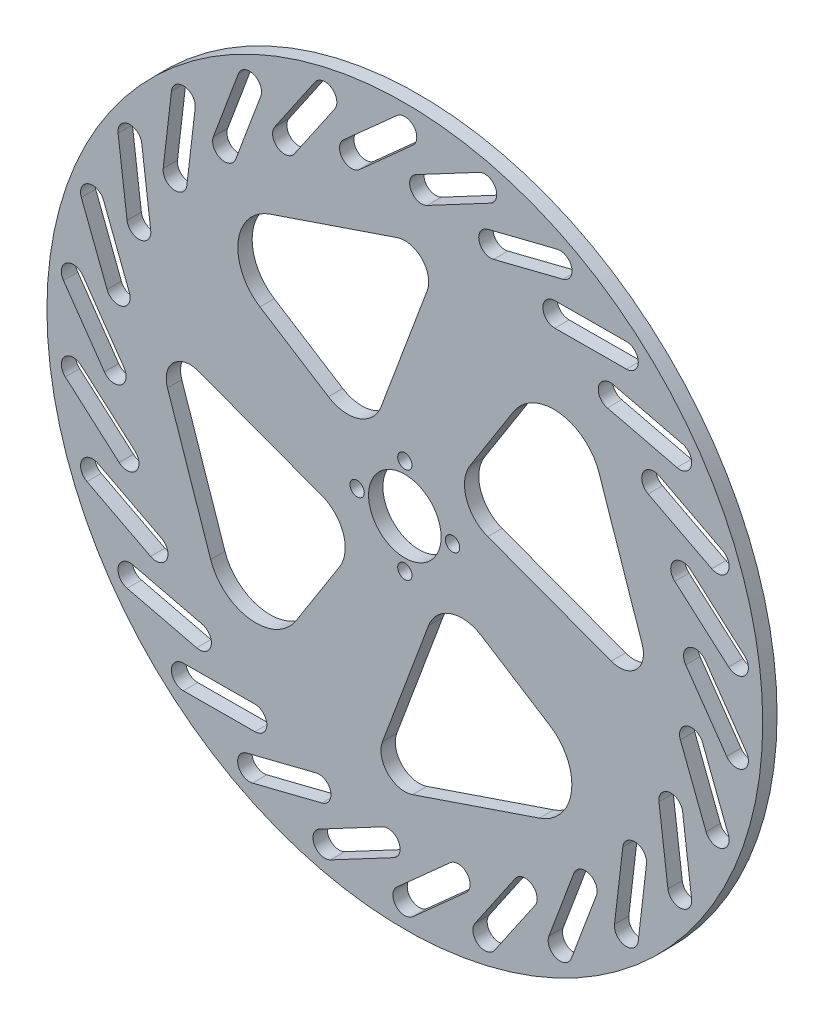
from build123d import *

# Parameters (mm, degrees)
SKETCH1_R           = 75
SKETCH1_R_2         = 7.6
SKETCH1_R_3         = 1.5
BOSS_EXTRUDE1_DEPTH = 3


with BuildPart() as part:
    # Sketch1 → Boss-Extrude1 (new body)
    with BuildSketch(Plane.XY):
        Circle(SKETCH1_R)
        Circle(SKETCH1_R_2, mode=Mode.SUBTRACT)
        with Locations((0, 10)):
            Circle(SKETCH1_R_3, mode=Mode.SUBTRACT)
        with Locations((10, 0)):
            Circle(SKETCH1_R_3, mode=Mode.SUBTRACT)
        with Locations((0, -10)):
            Circle(SKETCH1_R_3, mode=Mode.SUBTRACT)
        with Locations((-10, 0)):
            Circle(SKETCH1_R_3, mode=Mode.SUBTRACT)
        with BuildLine():
            Line((-4.973521873, 17.377290499), (4.684318752, 43.251526999))
            ThreePointArc((4.684318752, 43.251526999), (3.587665219, 48.482622328), (-1.608542655, 49.734193757))
            Line((-1.608542655, 49.734193757), (-28.21708531, 40.693377506))
            ThreePointArc((-28.21708531, 40.693377506), (-34.928892654, 32.415406165), (-30.364142129, 22.785441472))
            Line((-30.364142129, 22.785441472), (-16.023106597, 13.67033861))
            ThreePointArc((-16.023106597, 13.67033861), (-9.614537107, 12.889474929), (-4.973521873, 17.377290499))
        make_face(mode=Mode.SUBTRACT)
        with BuildLine():
            Line((22.785441472, 30.364142129), (13.67033861, 16.023106597))
            ThreePointArc((13.67033861, 16.023106597), (12.889474929, 9.614537107), (17.377290499, 4.973521873))
            Line((17.377290499, 4.973521873), (43.251526999, -4.684318752))
            ThreePointArc((43.251526999, -4.684318752), (48.482622328, -3.587665219), (49.734193757, 1.608542655))
            Line((49.734193757, 1.608542655), (40.693377506, 28.21708531))
            ThreePointArc((40.693377506, 28.21708531), (32.415406165, 34.928892654), (22.785441472, 30.364142129))
        make_face(mode=Mode.SUBTRACT)
        with BuildLine():
            Line((30.364142129, -22.785441472), (16.023106597, -13.67033861))
            ThreePointArc((16.023106597, -13.67033861), (9.614537107, -12.889474929), (4.973521873, -17.377290499))
            Line((4.973521873, -17.377290499), (-4.684318752, -43.251526999))
            ThreePointArc((-4.684318752, -43.251526999), (-3.587665219, -48.482622328), (1.608542655, -49.734193757))
            Line((1.608542655, -49.734193757), (28.21708531, -40.693377506))
            ThreePointArc((28.21708531, -40.693377506), (34.928892654, -32.415406165), (30.364142129, -22.785441472))
        make_face(mode=Mode.SUBTRACT)
        with BuildLine():
            Line((-22.785441472, -30.364142129), (-13.67033861, -16.023106597))
            ThreePointArc((-13.67033861, -16.023106597), (-12.889474929, -9.614537107), (-17.377290499, -4.973521873))
            Line((-17.377290499, -4.973521873), (-43.251526999, 4.684318752))
            ThreePointArc((-43.251526999, 4.684318752), (-48.482622328, 3.587665219), (-49.734193757, -1.608542655))
            Line((-49.734193757, -1.608542655), (-40.693377506, -28.21708531))
            ThreePointArc((-40.693377506, -28.21708531), (-32.415406165, -34.928892654), (-22.785441472, -30.364142129))
        make_face(mode=Mode.SUBTRACT)
        with BuildLine():
            Line((1.666666667, 68.136610019), (-9.513673221, 58.136610019))
            ThreePointArc((-9.513673221, 58.136610019), (-13.043729869, 58.333333333), (-12.847006554, 61.863389981))
            Line((-12.847006554, 61.863389981), (-1.666666667, 71.863389981))
            ThreePointArc((-1.666666667, 71.863389981), (1.863389981, 71.666666667), (1.666666667, 68.136610019))
        make_face(mode=Mode.SUBTRACT)
        with BuildLine():
            Line((17.924394451, 65.757824524), (4.675778279, 58.724036817))
            ThreePointArc((4.675778279, 58.724036817), (1.295377632, 59.759841562), (2.331182376, 63.140242208))
            Line((2.331182376, 63.140242208), (15.579798549, 70.174029915))
            ThreePointArc((15.579798549, 70.174029915), (18.960199196, 69.138225171), (17.924394451, 65.757824524))
        make_face(mode=Mode.SUBTRACT)
        with BuildLine():
            Line((33.140421583, 59.557433289), (18.59349054, 55.898636049))
            ThreePointArc((18.59349054, 55.898636049), (15.559202493, 57.713325016), (17.37389146, 60.747613063))
            Line((17.37389146, 60.747613063), (31.920822503, 64.406410303))
            ThreePointArc((31.920822503, 64.406410303), (34.95511055, 62.591721336), (33.140421583, 59.557433289))
        make_face(mode=Mode.SUBTRACT)
        with BuildLine():
            Line((46.430447873, 49.895780513), (31.430616716, 49.824609737))
            ThreePointArc((31.430616716, 49.824609737), (28.918783061, 52.312719801), (31.406893125, 54.824553456))
            Line((31.406893125, 54.824553456), (46.406724281, 54.895724231))
            ThreePointArc((46.406724281, 54.895724231), (48.918557936, 52.407614168), (46.430447873, 49.895780513))
        make_face(mode=Mode.SUBTRACT)
        with BuildLine():
            Line((57.0221053, 37.334366337), (42.441109695, 40.854958212))
            ThreePointArc((42.441109695, 40.854958212), (40.597709073, 43.871889459), (43.61464032, 45.715290081))
            Line((43.61464032, 45.715290081), (58.195635925, 42.194698205))
            ThreePointArc((58.195635925, 42.194698205), (60.039036547, 39.177766959), (57.0221053, 37.334366337))
        make_face(mode=Mode.SUBTRACT)
        with BuildLine():
            Line((64.299845234, 22.603214495), (50.985079644, 29.510965018))
            ThreePointArc((50.985079644, 29.510965018), (49.9172438, 32.88138437), (53.287663152, 33.949220214))
            Line((53.287663152, 33.949220214), (66.602428742, 27.041469691))
            ThreePointArc((66.602428742, 27.041469691), (67.670264586, 23.671050339), (64.299845234, 22.603214495))
        make_face(mode=Mode.SUBTRACT)
        with BuildLine():
            Line((67.840711884, 6.558445985), (56.565982089, 16.451901805))
            ThreePointArc((56.565982089, 16.451901805), (56.335769759, 19.97993274), (59.863800695, 20.21014507))
            Line((59.863800695, 20.21014507), (71.13853049, 10.31668925))
            ThreePointArc((71.13853049, 10.31668925), (71.368742819, 6.788658315), (67.840711884, 6.558445985))
        make_face(mode=Mode.SUBTRACT)
        with BuildLine():
            Line((67.438922949, -9.867475566), (58.859475263, 2.436713859))
            ThreePointArc((58.859475263, 2.436713859), (59.480265552, 5.917320044), (62.960871737, 5.296529754))
            Line((62.960871737, 5.296529754), (71.540319424, -7.00765967))
            ThreePointArc((71.540319424, -7.00765967), (70.919529135, -10.488265855), (67.438922949, -9.867475566))
        make_face(mode=Mode.SUBTRACT)
        with BuildLine():
            Line((63.117828944, -25.719935304), (57.73226968, -11.72008704))
            ThreePointArc((57.73226968, -11.72008704), (59.167984513, -8.489185785), (62.398885768, -9.924900618))
            Line((62.398885768, -9.924900618), (67.784445032, -23.924748882))
            ThreePointArc((67.784445032, -23.924748882), (66.348730199, -27.155650137), (63.117828944, -25.719935304))
        make_face(mode=Mode.SUBTRACT)
        with BuildLine():
            Line((55.128556144, -40.07764589), (53.249874432, -25.19575908))
            ThreePointArc((53.249874432, -25.19575908), (55.417075281, -22.402330993), (58.210503369, -24.569531843))
            Line((58.210503369, -24.569531843), (60.089185081, -39.451418652))
            ThreePointArc((60.089185081, -39.451418652), (57.921984231, -42.24484674), (55.128556144, -40.07764589))
        make_face(mode=Mode.SUBTRACT)
        with BuildLine():
            Line((43.935412046, -52.106189373), (45.672790037, -37.207145185))
            ThreePointArc((45.672790037, -37.207145185), (48.445527067, -35.013534153), (50.6391381, -37.786271183))
            Line((50.6391381, -37.786271183), (48.901760108, -52.685315371))
            ThreePointArc((48.901760108, -52.685315371), (46.129023078, -54.878926403), (43.935412046, -52.106189373))
        make_face(mode=Mode.SUBTRACT)
        with BuildLine():
            Line((30.188901497, -61.106510529), (35.441369099, -47.056187255))
            ThreePointArc((35.441369099, -47.056187255), (38.658500912, -45.589877977), (40.12481019, -48.807009789))
            Line((40.12481019, -48.807009789), (34.872342589, -62.857333063))
            ThreePointArc((34.872342589, -62.857333063), (31.655210776, -64.323642341), (30.188901497, -61.106510529))
        make_face(mode=Mode.SUBTRACT)
        with BuildLine():
            Line((14.687921727, -66.555543405), (23.150224613, -54.170494764))
            ThreePointArc((23.150224613, -54.170494764), (26.624783202, -53.516703805), (27.278574161, -56.991262393))
            Line((27.278574161, -56.991262393), (18.816271274, -69.376311034))
            ThreePointArc((18.816271274, -69.376311034), (15.341712686, -70.030101993), (14.687921727, -66.555543405))
        make_face(mode=Mode.SUBTRACT)
        with BuildLine():
            Line((-1.666666667, -68.136610019), (9.513673221, -58.136610019))
            ThreePointArc((9.513673221, -58.136610019), (13.043729869, -58.333333333), (12.847006554, -61.863389981))
            Line((12.847006554, -61.863389981), (1.666666667, -71.863389981))
            ThreePointArc((1.666666667, -71.863389981), (-1.863389981, -71.666666667), (-1.666666667, -68.136610019))
        make_face(mode=Mode.SUBTRACT)
        with BuildLine():
            Line((-17.924394451, -65.757824524), (-4.675778279, -58.724036817))
            ThreePointArc((-4.675778279, -58.724036817), (-1.295377632, -59.759841562), (-2.331182376, -63.140242208))
            Line((-2.331182376, -63.140242208), (-15.579798549, -70.174029915))
            ThreePointArc((-15.579798549, -70.174029915), (-18.960199196, -69.138225171), (-17.924394451, -65.757824524))
        make_face(mode=Mode.SUBTRACT)
        with BuildLine():
            Line((-33.140421583, -59.557433289), (-18.59349054, -55.898636049))
            ThreePointArc((-18.59349054, -55.898636049), (-15.559202493, -57.713325016), (-17.37389146, -60.747613063))
            Line((-17.37389146, -60.747613063), (-31.920822503, -64.406410303))
            ThreePointArc((-31.920822503, -64.406410303), (-34.95511055, -62.591721336), (-33.140421583, -59.557433289))
        make_face(mode=Mode.SUBTRACT)
        with BuildLine():
            Line((-46.430447873, -49.895780513), (-31.430616716, -49.824609737))
            ThreePointArc((-31.430616716, -49.824609737), (-28.918783061, -52.312719801), (-31.406893125, -54.824553456))
            Line((-31.406893125, -54.824553456), (-46.406724281, -54.895724231))
            ThreePointArc((-46.406724281, -54.895724231), (-48.918557936, -52.407614168), (-46.430447873, -49.895780513))
        make_face(mode=Mode.SUBTRACT)
        with BuildLine():
            Line((-57.0221053, -37.334366337), (-42.441109695, -40.854958212))
            ThreePointArc((-42.441109695, -40.854958212), (-40.597709073, -43.871889459), (-43.61464032, -45.715290081))
            Line((-43.61464032, -45.715290081), (-58.195635925, -42.194698205))
            ThreePointArc((-58.195635925, -42.194698205), (-60.039036547, -39.177766959), (-57.0221053, -37.334366337))
        make_face(mode=Mode.SUBTRACT)
        with BuildLine():
            Line((-64.299845234, -22.603214495), (-50.985079644, -29.510965018))
            ThreePointArc((-50.985079644, -29.510965018), (-49.9172438, -32.88138437), (-53.287663152, -33.949220214))
            Line((-53.287663152, -33.949220214), (-66.602428742, -27.041469691))
            ThreePointArc((-66.602428742, -27.041469691), (-67.670264586, -23.671050339), (-64.299845234, -22.603214495))
        make_face(mode=Mode.SUBTRACT)
        with BuildLine():
            Line((-67.840711884, -6.558445985), (-56.565982089, -16.451901805))
            ThreePointArc((-56.565982089, -16.451901805), (-56.335769759, -19.97993274), (-59.863800695, -20.21014507))
            Line((-59.863800695, -20.21014507), (-71.13853049, -10.31668925))
            ThreePointArc((-71.13853049, -10.31668925), (-71.368742819, -6.788658315), (-67.840711884, -6.558445985))
        make_face(mode=Mode.SUBTRACT)
        with BuildLine():
            Line((-67.438922949, 9.867475566), (-58.859475263, -2.436713859))
            ThreePointArc((-58.859475263, -2.436713859), (-59.480265552, -5.917320044), (-62.960871737, -5.296529754))
            Line((-62.960871737, -5.296529754), (-71.540319424, 7.00765967))
            ThreePointArc((-71.540319424, 7.00765967), (-70.919529135, 10.488265855), (-67.438922949, 9.867475566))
        make_face(mode=Mode.SUBTRACT)
        with BuildLine():
            Line((-63.117828944, 25.719935304), (-57.73226968, 11.72008704))
            ThreePointArc((-57.73226968, 11.72008704), (-59.167984513, 8.489185785), (-62.398885768, 9.924900618))
            Line((-62.398885768, 9.924900618), (-67.784445032, 23.924748882))
            ThreePointArc((-67.784445032, 23.924748882), (-66.348730199, 27.155650137), (-63.117828944, 25.719935304))
        make_face(mode=Mode.SUBTRACT)
        with BuildLine():
            Line((-55.128556144, 40.07764589), (-53.249874432, 25.19575908))
            ThreePointArc((-53.249874432, 25.19575908), (-55.417075281, 22.402330993), (-58.210503369, 24.569531843))
            Line((-58.210503369, 24.569531843), (-60.089185081, 39.451418652))
            ThreePointArc((-60.089185081, 39.451418652), (-57.921984231, 42.24484674), (-55.128556144, 40.07764589))
        make_face(mode=Mode.SUBTRACT)
        with BuildLine():
            Line((-43.935412046, 52.106189373), (-45.672790037, 37.207145185))
            ThreePointArc((-45.672790037, 37.207145185), (-48.445527067, 35.013534153), (-50.6391381, 37.786271183))
            Line((-50.6391381, 37.786271183), (-48.901760108, 52.685315371))
            ThreePointArc((-48.901760108, 52.685315371), (-46.129023078, 54.878926403), (-43.935412046, 52.106189373))
        make_face(mode=Mode.SUBTRACT)
        with BuildLine():
            Line((-30.188901497, 61.106510529), (-35.441369099, 47.056187255))
            ThreePointArc((-35.441369099, 47.056187255), (-38.658500912, 45.589877977), (-40.12481019, 48.807009789))
            Line((-40.12481019, 48.807009789), (-34.872342589, 62.857333063))
            ThreePointArc((-34.872342589, 62.857333063), (-31.655210776, 64.323642341), (-30.188901497, 61.106510529))
        make_face(mode=Mode.SUBTRACT)
        with BuildLine():
            Line((-14.687921727, 66.555543405), (-23.150224613, 54.170494764))
            ThreePointArc((-23.150224613, 54.170494764), (-26.624783202, 53.516703805), (-27.278574161, 56.991262393))
            Line((-27.278574161, 56.991262393), (-18.816271274, 69.376311034))
            ThreePointArc((-18.816271274, 69.376311034), (-15.341712686, 70.030101993), (-14.687921727, 66.555543405))
        make_face(mode=Mode.SUBTRACT)
    extrude(amount=BOSS_EXTRUDE1_DEPTH)


solid = part.part
